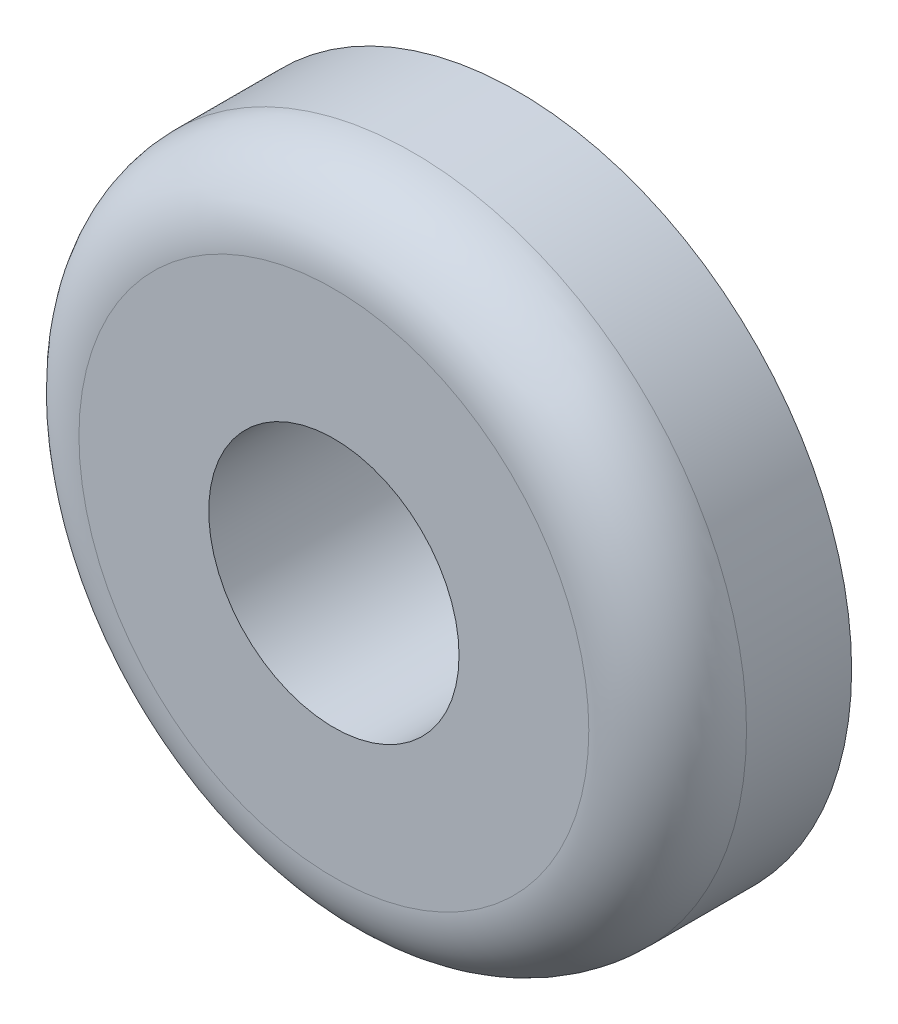
from build123d import *

# Parameters (mm, degrees)
SKETCH1_R           = 6.35
SKETCH1_R_2         = 2.38125
BOSS_EXTRUDE1_DEPTH = 3.5
FILLET1_R           = 1.5


with BuildPart() as part:
    # Sketch1 → Boss-Extrude1 (new body)
    with BuildSketch(Plane.XY):
        Circle(SKETCH1_R)
        Circle(SKETCH1_R_2, mode=Mode.SUBTRACT)
    extrude(amount=BOSS_EXTRUDE1_DEPTH)

    # Fillet1
    fillet1_edges = [part.edges().sort_by_distance(p)[0] for p in [
        (-6.35, 0, 3.5),
    ]]
    fillet(fillet1_edges, radius=FILLET1_R)


solid = part.part
